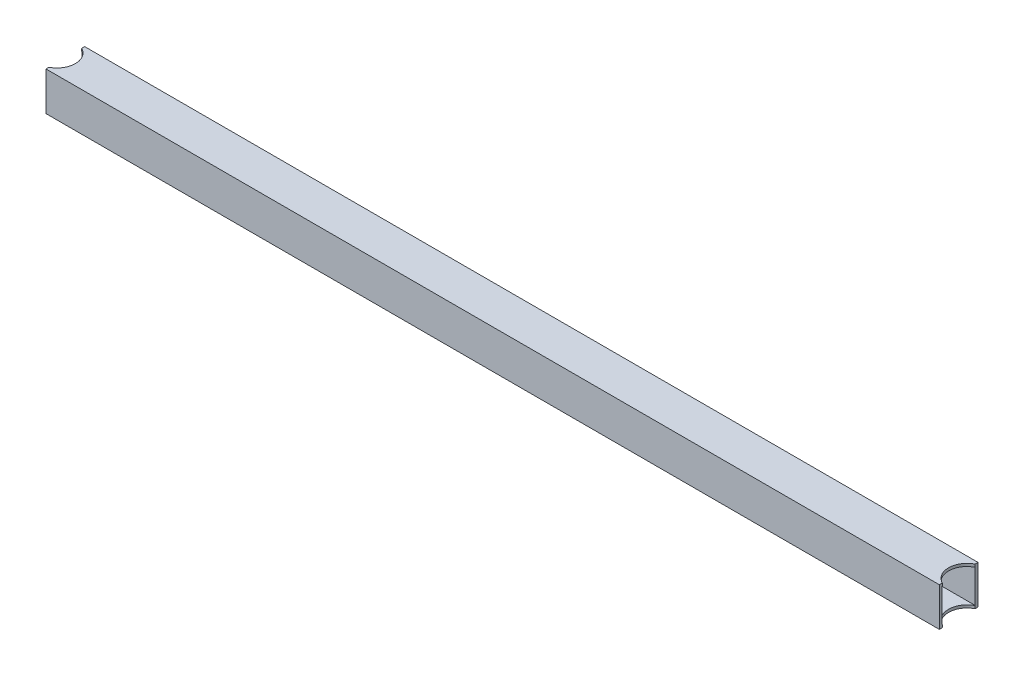
from build123d import *

# Parameters (mm, degrees)
BOSS_EXTRUDE1_DEPTH = 44.45
SKETCH3_W           = 38.1
SKETCH3_H           = 38.1
CUT_EXTRUDE1_DEPTH  = 1027.16


with BuildPart() as part:
    # Sketch2 → Boss-Extrude1 (new body)
    with BuildSketch(Plane(origin=(0, 0, 0), x_dir=(1, 0, 0), z_dir=(0, 1, 0))):
        with BuildLine():
            Line((513.08, 18.807580892), (513.08, 22.225))
            Line((513.08, 22.225), (-513.08, 22.225))
            Line((-513.08, 22.225), (-513.08, 18.807580892))
            ThreePointArc((-513.08, 18.807580892), (-504.64314077, 11.037315661), (-501.523, 0))
            ThreePointArc((-501.523, 0), (-504.64314077, -11.037315661), (-513.08, -18.807580892))
            Line((-513.08, -18.807580892), (-513.08, -22.225))
            Line((-513.08, -22.225), (513.08, -22.225))
            Line((513.08, -22.225), (513.08, -18.807580892))
            ThreePointArc((513.08, -18.807580892), (501.523, 0), (513.08, 18.807580892))
        make_face()
    extrude(amount=BOSS_EXTRUDE1_DEPTH)

    # Sketch3 → Cut-Extrude1 (cut, through all)
    with BuildSketch(Plane.ZY.offset(513.08)):
        with Locations((0, 22.225)):
            Rectangle(SKETCH3_W, SKETCH3_H)
    extrude(amount=-CUT_EXTRUDE1_DEPTH, mode=Mode.SUBTRACT)


solid = part.part
